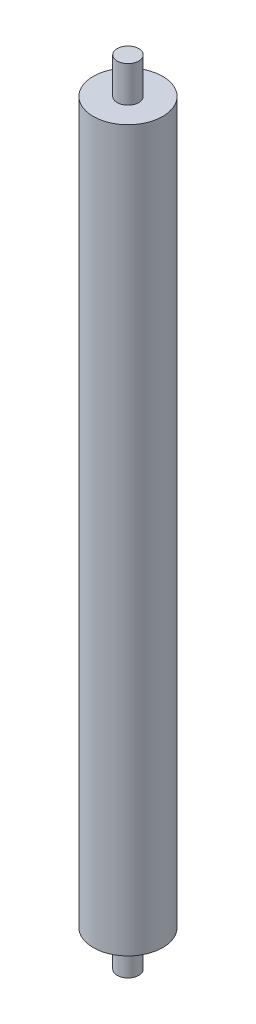
from build123d import *

# Parameters (mm, degrees)
SKETCH1_R                = 24.511
BOSS_EXTRUDE1_DEPTH      = 508
SKETCH2_R                = 7.62
BOSS_EXTRUDE2_DEPTH      = 25.4
BOSS_EXTRUDE2_DEPTH_BACK = 533.4


with BuildPart() as part:
    # Sketch1 → Boss-Extrude1 (new body)
    with BuildSketch(Plane(origin=(0, 0, 0), x_dir=(1, 0, 0), z_dir=(0, 1, 0))):
        Circle(SKETCH1_R)
    extrude(amount=BOSS_EXTRUDE1_DEPTH)

    # Sketch2 → Boss-Extrude2 (add, two sides)
    with BuildSketch(Plane.XZ) as boss_extrude2_sk:
        Circle(SKETCH2_R)
    extrude(amount=BOSS_EXTRUDE2_DEPTH)
    extrude(boss_extrude2_sk.sketch, amount=-BOSS_EXTRUDE2_DEPTH_BACK)


solid = part.part
